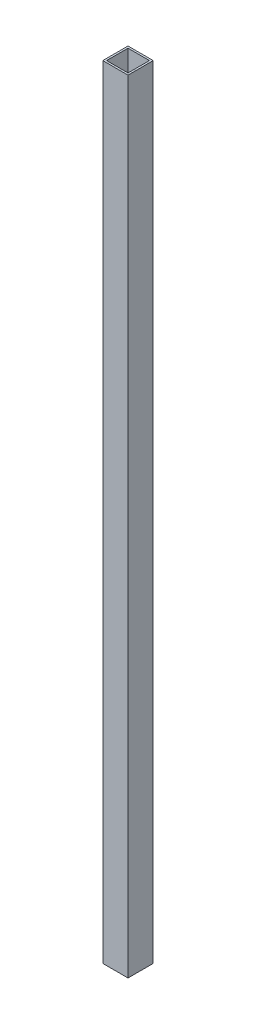
from build123d import *

# Parameters (mm, degrees)
SKETCH1_W           = 40
SKETCH1_H           = 40
BOSS_EXTRUDE1_DEPTH = 1240
SKETCH2_W           = 34
SKETCH2_H           = 34
CUT_EXTRUDE1_DEPTH  = 1241


with BuildPart() as part:
    # Sketch1 → Boss-Extrude1 (new body)
    with BuildSketch(Plane(origin=(0, 0, 0), x_dir=(1, 0, 0), z_dir=(0, 1, 0))):
        Rectangle(SKETCH1_W, SKETCH1_H)
    extrude(amount=BOSS_EXTRUDE1_DEPTH)

    # Sketch2 → Cut-Extrude1 (cut, through all)
    with BuildSketch(Plane(origin=(0, 1240, 0), x_dir=(1, 0, 0), z_dir=(0, 1, 0))):
        Rectangle(SKETCH2_W, SKETCH2_H)
    extrude(amount=-CUT_EXTRUDE1_DEPTH, mode=Mode.SUBTRACT)


solid = part.part
